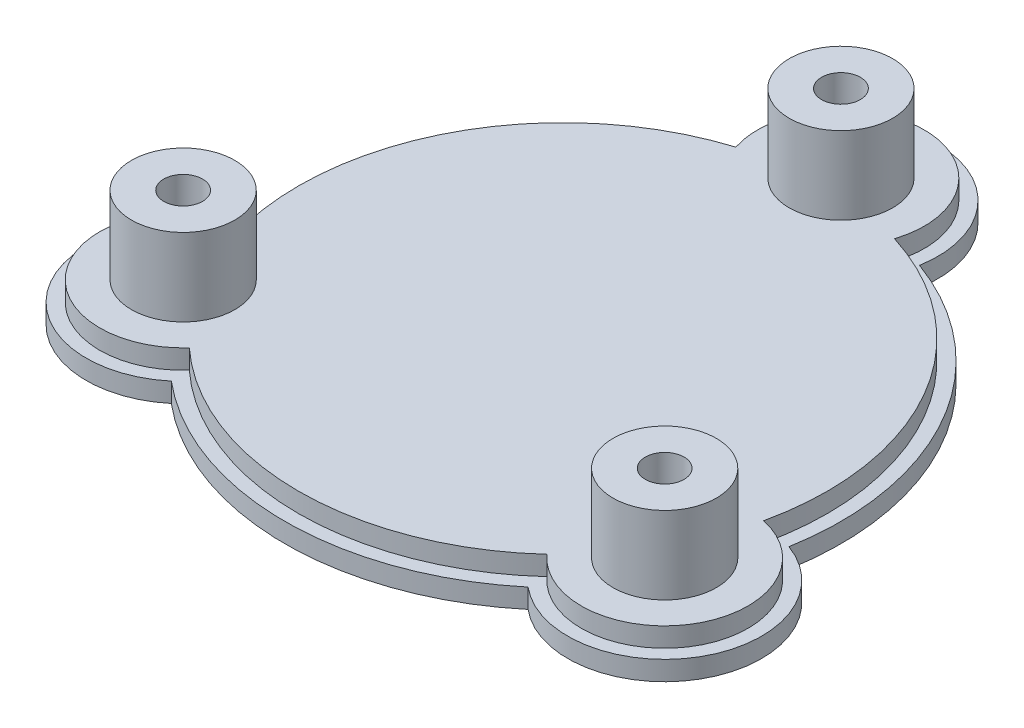
from build123d import *

# Parameters (mm, degrees)
SKETCH1_R           = 6
BOSS_EXTRUDE1_DEPTH = 3
SKETCH1_3_R         = 8
SKETCH1_3_R_2       = 6
BOSS_EXTRUDE2_DEPTH = 18
SKETCH2_R           = 8
BOSS_EXTRUDE3_DEPTH = 3
BOSS_EXTRUDE4_START = -6
SKETCH3_R           = 6
SKETCH3_R_2         = 3
BOSS_EXTRUDE4_DEPTH = 6


with BuildPart() as part:
    # Sketch1 → Boss-Extrude1 (new body)
    with BuildSketch(Plane(origin=(0, 0, 0), x_dir=(1, 0, 0), z_dir=(0, 1, 0))):
        with BuildLine():
            ThreePointArc((42.358365189, -7.400601228), (37.239092363, 21.5), (14.770073928, 40.38372093))
            ThreePointArc((14.770073928, 40.38372093), (0, 58), (-14.770073928, 40.38372093))
            ThreePointArc((-14.770073928, 40.38372093), (-37.239092363, 21.5), (-42.358365189, -7.400601228))
            ThreePointArc((-42.358365189, -7.400601228), (-50.229473419, -29), (-27.588291261, -32.983119702))
            ThreePointArc((-27.588291261, -32.983119702), (0, -43), (27.588291261, -32.983119702))
            ThreePointArc((27.588291261, -32.983119702), (50.22947342, -29), (42.358365189, -7.400601228))
        make_face()
        with Locations((37.239092363, -21.5)):
            Circle(SKETCH1_R, mode=Mode.SUBTRACT)
        with Locations((-37.239092363, -21.5)):
            Circle(SKETCH1_R, mode=Mode.SUBTRACT)
        with Locations((0, 43)):
            Circle(SKETCH1_R, mode=Mode.SUBTRACT)
    extrude(amount=BOSS_EXTRUDE1_DEPTH)

    # Sketch1_3 → Boss-Extrude2 (add)
    # profile 1 of 3: a face of its own
    with BuildSketch(Plane(origin=(0, 0, 0), x_dir=(1, 0, 0), z_dir=(0, 1, 0))):
        with Locations((0, 43)):
            Circle(SKETCH1_3_R)
        with Locations((0, 43)):
            Circle(SKETCH1_3_R_2, mode=Mode.SUBTRACT)
    # profile 2 of 3: a face of its own
    with BuildSketch(Plane(origin=(0, 0, 0), x_dir=(1, 0, 0), z_dir=(0, 1, 0))):
        with Locations((37.239092363, -21.5)):
            Circle(SKETCH1_3_R)
        with Locations((37.239092363, -21.5)):
            Circle(SKETCH1_3_R_2, mode=Mode.SUBTRACT)
    # profile 3 of 3: a face of its own
    with BuildSketch(Plane(origin=(0, 0, 0), x_dir=(1, 0, 0), z_dir=(0, 1, 0))):
        with Locations((-37.239092363, -21.5)):
            Circle(SKETCH1_3_R)
        with Locations((-37.239092363, -21.5)):
            Circle(SKETCH1_3_R_2, mode=Mode.SUBTRACT)
    extrude(amount=BOSS_EXTRUDE2_DEPTH)

    # Sketch2 → Boss-Extrude3 (add)
    with BuildSketch(Plane(origin=(0, 3, 0), x_dir=(1, 0, 0), z_dir=(0, 1, 0))):
        with BuildLine():
            ThreePointArc((12.269472994, 39.01627907), (0, 55.9), (-12.269472994, 39.01627907))
            ThreePointArc((-12.269472994, 39.01627907), (-35.420439015, 20.45), (-39.923825333, -8.882464231))
            ThreePointArc((-39.923825333, -8.882464231), (-48.410820072, -27.95), (-27.654352339, -30.133814839))
            ThreePointArc((-27.654352339, -30.133814839), (0, -40.9), (27.654352339, -30.133814839))
            ThreePointArc((27.654352339, -30.133814839), (48.410820072, -27.95), (39.923825333, -8.882464231))
            ThreePointArc((39.923825333, -8.882464231), (35.420439015, 20.45), (12.269472994, 39.01627907))
        make_face()
        with Locations((-37.239092363, -21.5)):
            Circle(SKETCH2_R, mode=Mode.SUBTRACT)
        with Locations((37.239092363, -21.5)):
            Circle(SKETCH2_R, mode=Mode.SUBTRACT)
        with Locations((0, 43)):
            Circle(SKETCH2_R, mode=Mode.SUBTRACT)
    extrude(amount=BOSS_EXTRUDE3_DEPTH)

    # Sketch3 → Boss-Extrude4 (add)
    # profile 1 of 3: a face of its own
    with BuildSketch(Plane(origin=(0, 18, 0), x_dir=(1, 0, 0), z_dir=(0, 1, 0)).offset(BOSS_EXTRUDE4_START)):
        with Locations((-37.239092363, -21.5)):
            Circle(SKETCH3_R)
        with Locations((-37.239092363, -21.5)):
            Circle(SKETCH3_R_2, mode=Mode.SUBTRACT)
    # profile 2 of 3: a face of its own
    with BuildSketch(Plane(origin=(0, 18, 0), x_dir=(1, 0, 0), z_dir=(0, 1, 0)).offset(BOSS_EXTRUDE4_START)):
        with Locations((0, 43)):
            Circle(SKETCH3_R)
        with Locations((0, 43)):
            Circle(SKETCH3_R_2, mode=Mode.SUBTRACT)
    # profile 3 of 3: a face of its own
    with BuildSketch(Plane(origin=(0, 18, 0), x_dir=(1, 0, 0), z_dir=(0, 1, 0)).offset(BOSS_EXTRUDE4_START)):
        with Locations((37.239092363, -21.5)):
            Circle(SKETCH3_R)
        with Locations((37.239092363, -21.5)):
            Circle(SKETCH3_R_2, mode=Mode.SUBTRACT)
    extrude(amount=BOSS_EXTRUDE4_DEPTH)


solid = part.part
